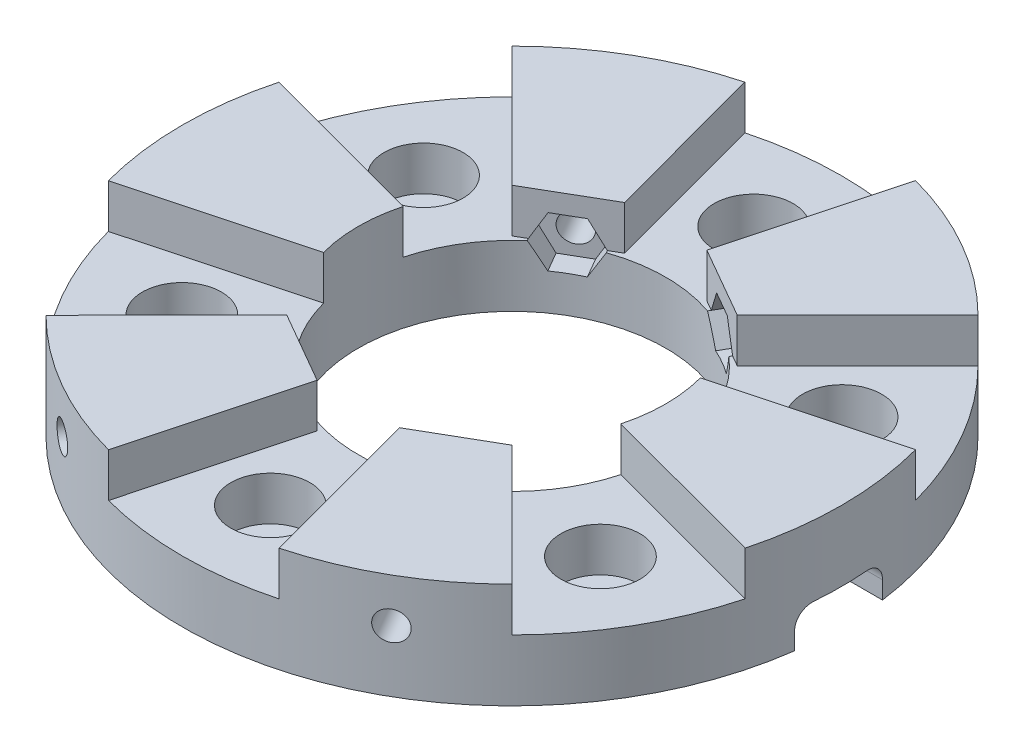
from build123d import *
from build123d.topology import SkipClean

# Parameters (mm, degrees)
SKETCH1_R                = 37.5
SKETCH1_R_2              = 2.3
BOSS_EXTRUDE1_DEPTH      = 2
SKETCH2_R                = 37.5
SKETCH2_R_2              = 4.5
BOSS_EXTRUDE2_DEPTH      = 5
BOSS_EXTRUDE3_DEPTH      = 5
CUT_EXTRUDE1_START       = -7
SKETCH4_R                = 17.5
CUT_EXTRUDE1_DEPTH       = 7
CUT_EXTRUDE2_DEPTH       = 7
CUT_EXTRUDE2_DEPTH_BACK  = 2.5
CUT_EXTRUDE4_DEPTH       = 3
CUT_EXTRUDE4_DEPTH_BACK  = 2.5
SKETCH10_R               = 1.65
CUT_EXTRUDE7_DEPTH       = 20
SKETCH9_R                = 1.65
CUT_EXTRUDE6_DEPTH       = 20
CUT_EXTRUDE8_DEPTH       = 4
CUT_EXTRUDE9_DEPTH       = 10
CUT_EXTRUDE9_DEPTH_BACK  = 2.5
SKETCH16_R               = 1.65
CUT_EXTRUDE10_DEPTH      = 20
CUT_EXTRUDE11_DEPTH      = 10
CUT_EXTRUDE11_DEPTH_BACK = 2.5
SKETCH18_R               = 1.65
CUT_EXTRUDE12_DEPTH      = 20
FILLET1_R                = 2


with BuildPart() as part:
    # Sketch1 → Boss-Extrude1 (new body)
    with BuildSketch(Plane(origin=(0, 0, 0), x_dir=(1, 0, 0), z_dir=(0, 1, 0))):
        Circle(SKETCH1_R)
        with Locations((0, 27.5)):
            Circle(SKETCH1_R_2, mode=Mode.SUBTRACT)
        with Locations((23.815698604, 13.75)):
            Circle(SKETCH1_R_2, mode=Mode.SUBTRACT)
        with Locations((23.815698604, -13.75)):
            Circle(SKETCH1_R_2, mode=Mode.SUBTRACT)
        with Locations((0, -27.5)):
            Circle(SKETCH1_R_2, mode=Mode.SUBTRACT)
        with Locations((-23.815698604, -13.75)):
            Circle(SKETCH1_R_2, mode=Mode.SUBTRACT)
        with Locations((-23.815698604, 13.75)):
            Circle(SKETCH1_R_2, mode=Mode.SUBTRACT)
    extrude(amount=BOSS_EXTRUDE1_DEPTH)

    # Sketch2 → Boss-Extrude2 (add)
    with BuildSketch(Plane(origin=(0, 2, 0), x_dir=(1, 0, 0), z_dir=(0, 1, 0))):
        Circle(SKETCH2_R)
        with Locations((-23.815698604, -13.75)):
            Circle(SKETCH2_R_2, mode=Mode.SUBTRACT)
        with Locations((0, -27.5)):
            Circle(SKETCH2_R_2, mode=Mode.SUBTRACT)
        with Locations((23.815698604, -13.75)):
            Circle(SKETCH2_R_2, mode=Mode.SUBTRACT)
        with Locations((-23.815698604, 13.75)):
            Circle(SKETCH2_R_2, mode=Mode.SUBTRACT)
        with Locations((23.815698604, 13.75)):
            Circle(SKETCH2_R_2, mode=Mode.SUBTRACT)
        with Locations((0, 27.5)):
            Circle(SKETCH2_R_2, mode=Mode.SUBTRACT)
    extrude(amount=BOSS_EXTRUDE2_DEPTH)

    # Sketch3 → Boss-Extrude3 (add)
    with BuildSketch(Plane(origin=(0, 7, 0), x_dir=(1, 0, 0), z_dir=(0, 1, 0))):
        with BuildLine():
            ThreePointArc((-16.901898546, -4.536058371), (-17.499998615, -0.006962688), (-16.905502698, 4.52260749))
            Line((-16.905502698, 4.52260749), (-36.226077211, 9.691301765))
            ThreePointArc((-36.226077211, 9.691301765), (-37.499997032, -0.014920046), (-36.218354027, -9.720125081))
            Line((-36.218354027, -9.720125081), (-16.901898546, -4.536058371))
        make_face()
        with BuildLine():
            ThreePointArc((-9.720125081, 36.218354027), (-18.762919655, 32.468490048), (-26.527052262, 26.50595213))
            Line((-26.527052262, 26.50595213), (-12.810223172, 12.800033673))
            Line((-12.810223172, 12.800033673), (-4.698199739, 17.506056765))
            Line((-4.698199739, 17.506056765), (-9.720125081, 36.218354027))
        make_face()
        with BuildLine():
            ThreePointArc((16.901898546, 4.536058371), (17.499998615, 0.006962688), (16.905502698, -4.52260749))
            Line((16.905502698, -4.52260749), (36.226077211, -9.691301765))
            ThreePointArc((36.226077211, -9.691301765), (37.499997032, 0.014920046), (36.218354027, 9.720125081))
            Line((36.218354027, 9.720125081), (16.901898546, 4.536058371))
        make_face()
        with BuildLine():
            Line((-12.805791077, -12.81598516), (-26.50595213, -26.527052262))
            ThreePointArc((-26.50595213, -26.527052262), (-18.737077377, -32.483410095), (-9.691301765, -36.226077211))
            Line((-9.691301765, -36.226077211), (-4.682147808, -17.501864262))
            Line((-4.682147808, -17.501864262), (-12.805791077, -12.81598516))
        make_face()
        with BuildLine():
            Line((4.680172315, 17.49447987), (12.811230656, 12.82142907))
            Line((12.811230656, 12.82142907), (26.50595213, 26.527052262))
            ThreePointArc((26.50595213, 26.527052262), (18.737077377, 32.483410095), (9.691301765, 36.226077211))
            Line((9.691301765, 36.226077211), (4.680172315, 17.49447987))
        make_face()
        with BuildLine():
            Line((12.819708432, -12.809511387), (4.694715176, -17.493072864))
            Line((4.694715176, -17.493072864), (9.720125081, -36.218354027))
            ThreePointArc((9.720125081, -36.218354027), (18.762919655, -32.468490048), (26.527052262, -26.50595213))
            Line((26.527052262, -26.50595213), (12.819708432, -12.809511387))
        make_face()
    extrude(amount=BOSS_EXTRUDE3_DEPTH)

    # Sketch4 → Cut-Extrude1 (cut)
    with SkipClean():  # the faces are left unmerged after this step: merging them gives an invalid solid
        with BuildSketch(Plane(origin=(0, 7, 0), x_dir=(1, 0, 0), z_dir=(0, 1, 0)).offset(CUT_EXTRUDE1_START)):
            Circle(SKETCH4_R)
        extrude(amount=CUT_EXTRUDE1_DEPTH, mode=Mode.SUBTRACT)

    # Sketch5 → Cut-Extrude2 (cut, two sides: drawn at the far end of the back side and taken through both)
    with SkipClean():  # the faces are left unmerged after this step: merging them gives an invalid solid
        with BuildSketch(Plane(origin=(-8.743969443, 0, 15.158924711), x_dir=(-0.8662242691872709, 0, -0.49965539671955755), z_dir=(0.49965539671955755, 0, -0.8662242691872709)).offset(-CUT_EXTRUDE2_DEPTH_BACK)):
            Polygon((-1.645448267, 9.85), (-3.290896534, 7), (-1.645448267, 4.15), (1.645448267, 4.15), (3.290896534, 7), (1.645448267, 9.85), align=None)
        extrude(amount=CUT_EXTRUDE2_DEPTH + CUT_EXTRUDE2_DEPTH_BACK, mode=Mode.SUBTRACT)

    # Sketch7 → Cut-Extrude4 (cut, two sides: drawn at the far end of the back side and taken through both)
    with SkipClean():  # the faces are left unmerged after this step: merging them gives an invalid solid
        with BuildSketch(Plane(origin=(8.739633736, 0, 15.161424807), x_dir=(-0.8663671318105545, 0, 0.49940764203038923), z_dir=(-0.49940764203038923, 0, -0.8663671318105545)).offset(-CUT_EXTRUDE4_DEPTH_BACK)):
            Polygon((-1.665737666, 9.85), (-3.311185933, 7), (-1.665737666, 4.15), (1.625158868, 4.15), (3.270607136, 7), (1.625158868, 9.85), align=None)
        extrude(amount=CUT_EXTRUDE4_DEPTH + CUT_EXTRUDE4_DEPTH_BACK, mode=Mode.SUBTRACT)

    # Sketch10 → Cut-Extrude7 (cut)
    with SkipClean():  # the faces are left unmerged after this step: merging them gives an invalid solid
        with BuildSketch(Plane(origin=(8.739633736, 0, 15.161424807), x_dir=(-0.8663671318105323, 0, 0.49940764203042776), z_dir=(-0.4994076420304278, 0, -0.8663671318105324))):
            with Locations((-0.020289399, 7)):
                Circle(SKETCH10_R)
        extrude(amount=-CUT_EXTRUDE7_DEPTH, mode=Mode.SUBTRACT)

    # Sketch9 → Cut-Extrude6 (cut)
    with SkipClean():  # the faces are left unmerged after this step: merging them gives an invalid solid
        with BuildSketch(Plane(origin=(-9.993107934, 0, 17.324485384), x_dir=(-0.866224269187271, 0, -0.4996553967195575), z_dir=(0.49965539671955744, 0, -0.8662242691872709))):
            with Locations((0, 6.9)):
                Circle(SKETCH9_R)
        extrude(amount=-CUT_EXTRUDE6_DEPTH, mode=Mode.SUBTRACT)

    # Sketch14 → Cut-Extrude8 (cut)
    with SkipClean():  # the faces are left unmerged after this step: merging them gives an invalid solid
        with BuildSketch(Plane.XZ):
            with BuildLine():
                Line((16.770509831, -5), (37.165171868, -5))
                ThreePointArc((37.165171868, -5), (37.5, 0), (37.165171868, 5))
                Line((37.165171868, 5), (16.770509831, 5))
                ThreePointArc((16.770509831, 5), (17.5, 0), (16.770509831, -5))
            make_face()
        extrude(amount=-CUT_EXTRUDE8_DEPTH, mode=Mode.SUBTRACT)

    # Sketch15 → Cut-Extrude9 (cut, two sides: drawn at the far end of the back side and taken through both)
    with SkipClean():  # the faces are left unmerged after this step: merging them gives an invalid solid
        with BuildSketch(Plane(origin=(-8.781531952, 0, -15.137195796), x_dir=(0.8649826169348818, 0, -0.5018018258241831), z_dir=(0.5018018258241831, 0, 0.8649826169348818)).offset(-CUT_EXTRUDE9_DEPTH_BACK)):
            Polygon((-1.645448267, 9.85), (-3.290896534, 7), (-1.645448267, 4.15), (1.645448267, 4.15), (3.290896534, 7), (1.645448267, 9.85), align=None)
        extrude(amount=CUT_EXTRUDE9_DEPTH + CUT_EXTRUDE9_DEPTH_BACK, mode=Mode.SUBTRACT)

    # Sketch16 → Cut-Extrude10 (cut)
    with SkipClean():  # the faces are left unmerged after this step: merging them gives an invalid solid
        with BuildSketch(Plane(origin=(-10.036036516, 0, -17.299652339), x_dir=(0.8649826169348817, 0, -0.5018018258241831), z_dir=(0.5018018258241831, 0, 0.8649826169348817))):
            with Locations((0, 7)):
                Circle(SKETCH16_R)
        extrude(amount=-CUT_EXTRUDE10_DEPTH, mode=Mode.SUBTRACT)

    # Sketch17 → Cut-Extrude11 (cut, two sides: drawn at the far end of the back side and taken through both)
    with SkipClean():  # the faces are left unmerged after this step: merging them gives an invalid solid
        with BuildSketch(Plane(origin=(8.720008177, 0, -15.17272083), x_dir=(0.8670126188794308, 0, 0.4982861815300832), z_dir=(-0.49828618153008314, 0, 0.8670126188794307)).offset(-CUT_EXTRUDE11_DEPTH_BACK)):
            Polygon((3.290896534, 7), (1.645448267, 9.85), (-1.645448267, 9.85), (-3.290896534, 7), (-1.645448267, 4.15), (1.645448267, 4.15), align=None)
        extrude(amount=CUT_EXTRUDE11_DEPTH + CUT_EXTRUDE11_DEPTH_BACK, mode=Mode.SUBTRACT)

    # Sketch18 → Cut-Extrude12 (cut)
    with SkipClean():  # the faces are left unmerged after this step: merging them gives an invalid solid
        with BuildSketch(Plane(origin=(9.965723631, 0, -17.340252378), x_dir=(0.8670126188794304, 0, 0.4982861815300839), z_dir=(-0.49828618153008386, 0, 0.8670126188794303))):
            with Locations((0, 7)):
                Circle(SKETCH18_R)
        extrude(amount=-CUT_EXTRUDE12_DEPTH, mode=Mode.SUBTRACT)

    # Fillet1
    fillet1_edges = [part.edges().sort_by_distance(p)[0] for p in [
        (26.96784085, 4, -5),
        (26.96784085, 4, 5),
    ]]
    fillet(fillet1_edges, radius=FILLET1_R)


solid = part.part
